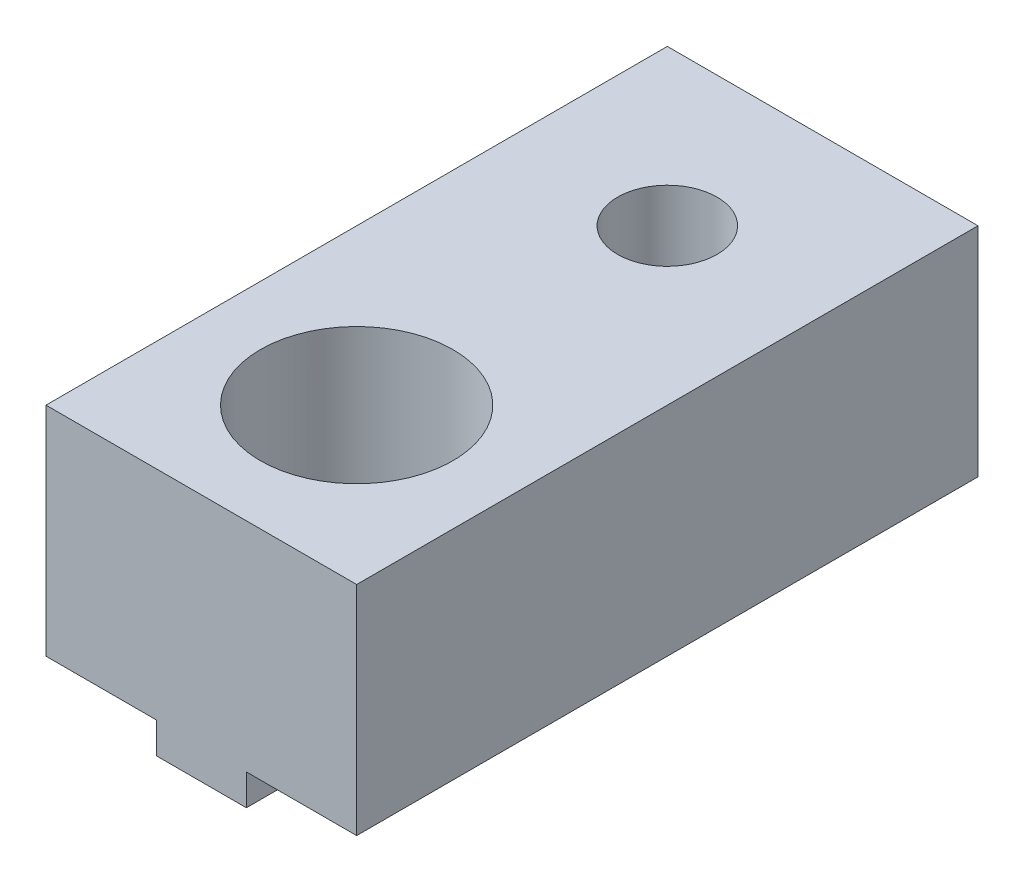
from build123d import *

# Parameters (mm, degrees)
BOSS_EXTRUDE1_DEPTH = 20
SKETCH2_R           = 3.1
CUT_EXTRUDE1_DEPTH  = 9
SKETCH4_R           = 1.6
CUT_EXTRUDE3_DEPTH  = 9


with BuildPart() as part:
    # Sketch1 → Boss-Extrude1 (new body)
    with BuildSketch(Plane.XY):
        Polygon((-5, 0), (-1.45, 0), (-1.45, -1), (1.45, -1), (1.45, 0), (5, 0), (5, 7), (-5, 7), align=None)
    extrude(amount=BOSS_EXTRUDE1_DEPTH)

    # Sketch2 → Cut-Extrude1 (cut, through all)
    with BuildSketch(Plane(origin=(0, 7, 0), x_dir=(1, 0, 0), z_dir=(0, 1, 0))):
        with Locations((0, -15)):
            Circle(SKETCH2_R)
    extrude(amount=-CUT_EXTRUDE1_DEPTH, mode=Mode.SUBTRACT)

    # Sketch4 → Cut-Extrude3 (cut, through all)
    with BuildSketch(Plane(origin=(0, 7, 0), x_dir=(1, 0, 0), z_dir=(0, 1, 0))):
        with Locations((0, -5)):
            Circle(SKETCH4_R)
    extrude(amount=-CUT_EXTRUDE3_DEPTH, mode=Mode.SUBTRACT)


solid = part.part
